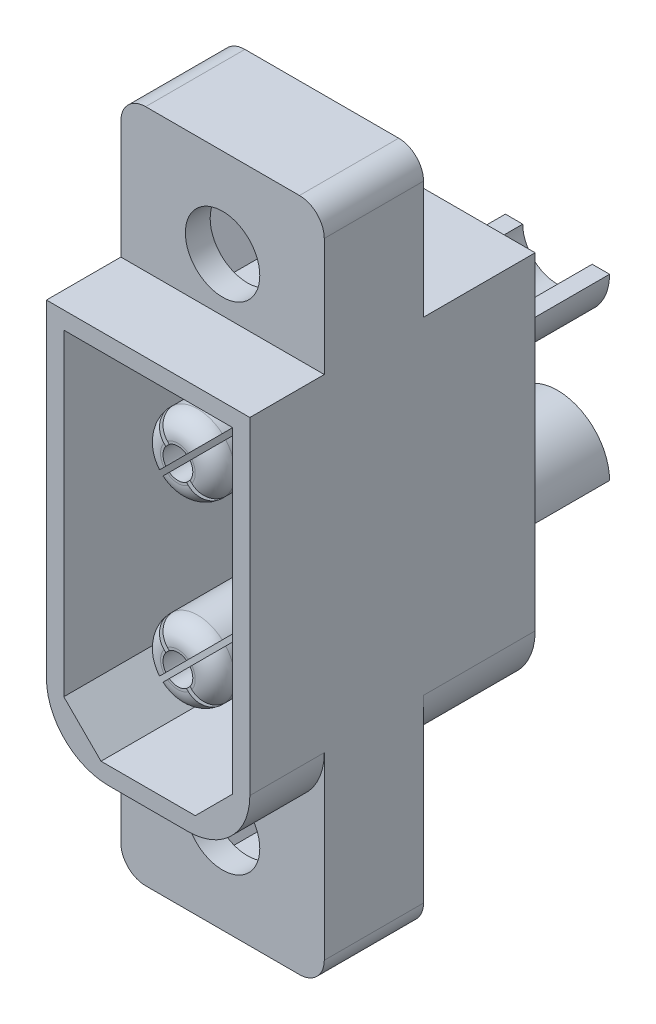
from build123d import *

# Parameters (mm, degrees)
ESTRUSIONE_ESTRUSIONE1_DEPTH  = 4
SCHIZZO2_R                    = 1.5
TAGLIO_ESTRUSIONE1_DEPTH      = 1
TAGLIO_ESTRUSIONE1_DEPTH_BACK = 5
ESTRUSIONE_ESTRUSIONE3_DEPTH  = 3
ESTRUSIONE_ESTRUSIONE4_DEPTH  = 4.5
TAGLIO_ESTRUSIONE2_DEPTH      = 9.5
TAGLIO_ESTRUSIONE3_DEPTH      = 1
SCHIZZO8_R                    = 2.1
ESTRUSIONE_ESTRUSIONE5_DEPTH  = 6
SCHIZZO9_W                    = 5.274732364
SCHIZZO9_H                    = 2.507546262
TAGLIO_ESTRUSIONE4_DEPTH      = 3.2
SCHIZZO10_R                   = 1.4
TAGLIO_ESTRUSIONE5_DEPTH      = 6
RACCORDO1_R                   = 1
TAGLIO_ESTRUSIONE6_DEPTH      = 6
SCHIZZO12_R                   = 1.5
ESTRUSIONE_ESTRUSIONE6_DEPTH  = 8.3
RACCORDO2_R                   = 0.8
TAGLIO_ESTRUSIONE7_DEPTH      = 7
TAGLIO_ESTRUSIONE8_DEPTH      = 3


with BuildPart() as part:
    # Schizzo1 → Estrusione-Estrusione1 (new body)
    with BuildSketch(Plane.XY):
        with BuildLine():
            Line((-3.1, 13.6), (3.1, 13.6))
            ThreePointArc((3.1, 13.6), (3.807106781, 13.307106781), (4.1, 12.6))
            Line((4.1, 12.6), (4.1, -12.6))
            ThreePointArc((4.1, -12.6), (3.807106781, -13.307106781), (3.1, -13.6))
            Line((3.1, -13.6), (-3.1, -13.6))
            ThreePointArc((-3.1, -13.6), (-3.807106781, -13.307106781), (-4.1, -12.6))
            Line((-4.1, -12.6), (-4.1, 12.6))
            ThreePointArc((-4.1, 12.6), (-3.807106781, 13.307106781), (-3.1, 13.6))
        make_face()
    extrude(amount=ESTRUSIONE_ESTRUSIONE1_DEPTH)

    # Schizzo2 → Taglio-Estrusione1 (cut, two sides)
    with BuildSketch(Plane.XY.offset(4)) as taglio_estrusione1_sk:
        with Locations((0, 10)):
            Circle(SCHIZZO2_R)
        with Locations((0, -10)):
            Circle(SCHIZZO2_R)
    extrude(amount=TAGLIO_ESTRUSIONE1_DEPTH, mode=Mode.SUBTRACT)
    extrude(taglio_estrusione1_sk.sketch, amount=-TAGLIO_ESTRUSIONE1_DEPTH_BACK, mode=Mode.SUBTRACT)

    # Schizzo4 → Estrusione-Estrusione3 (add)
    with BuildSketch(Plane.XY.offset(4)):
        with BuildLine():
            Line((-4.1, 7.85), (4.1, 7.85))
            Line((4.1, 7.85), (4.1, -5.35))
            ThreePointArc((4.1, -5.35), (3.367766953, -7.117766953), (1.6, -7.85))
            Line((1.6, -7.85), (-1.6, -7.85))
            ThreePointArc((-1.6, -7.85), (-3.367766953, -7.117766953), (-4.1, -5.35))
            Line((-4.1, -5.35), (-4.1, 7.85))
        make_face()
    extrude(amount=ESTRUSIONE_ESTRUSIONE3_DEPTH)

    # Schizzo5 → Estrusione-Estrusione4 (add)
    with BuildSketch(Plane(origin=(0, 0, 0), x_dir=(-1, 0, 0), z_dir=(0, 0, -1))):
        with BuildLine():
            Line((-1.6, -7.85), (1.6, -7.85))
            ThreePointArc((1.6, -7.85), (3.367766953, -7.117766953), (4.1, -5.35))
            Line((4.1, -5.35), (4.1, 7.85))
            Line((4.1, 7.85), (-4.1, 7.85))
            Line((-4.1, 7.85), (-4.1, -5.35))
            ThreePointArc((-4.1, -5.35), (-3.367766953, -7.117766953), (-1.6, -7.85))
        make_face()
    extrude(amount=ESTRUSIONE_ESTRUSIONE4_DEPTH)

    # Schizzo6 → Taglio-Estrusione2 (cut)
    with BuildSketch(Plane.XY.offset(7)):
        Polygon((1.9, -7.15), (3.4, -5.65), (3.4, 7.15), (-3.4, 7.15), (-3.4, -5.65), (-1.9, -7.15), align=None)
    extrude(amount=-TAGLIO_ESTRUSIONE2_DEPTH, mode=Mode.SUBTRACT)

    # Schizzo7 → Taglio-Estrusione3 (cut)
    with BuildSketch(Plane(origin=(0, 0, -4.5), x_dir=(-1, 0, 0), z_dir=(0, 0, -1))):
        with BuildLine():
            Line((3.4, -5.35), (3.4, 7.15))
            Line((3.4, 7.15), (-3.4, 7.15))
            Line((-3.4, 7.15), (-3.4, -5.35))
            ThreePointArc((-3.4, -5.35), (-2.872792206, -6.622792206), (-1.6, -7.15))
            Line((-1.6, -7.15), (1.6, -7.15))
            ThreePointArc((1.6, -7.15), (2.872792206, -6.622792206), (3.4, -5.35))
        make_face()
    extrude(amount=-TAGLIO_ESTRUSIONE3_DEPTH, mode=Mode.SUBTRACT)

    # Schizzo8 → Estrusione-Estrusione5 (add)
    with BuildSketch(Plane(origin=(0, 0, -3.5), x_dir=(-1, 0, 0), z_dir=(0, 0, -1))):
        with Locations((0, -3.6)):
            Circle(SCHIZZO8_R)
        with Locations((0, 3.6)):
            Circle(SCHIZZO8_R)
    extrude(amount=ESTRUSIONE_ESTRUSIONE5_DEPTH)

    # Schizzo9 → Taglio-Estrusione4 (cut)
    with BuildSketch(Plane(origin=(0, 0, -9.5), x_dir=(-1, 0, 0), z_dir=(0, 0, -1))):
        Polygon((2.1, 3.6), (-2.1, 3.6), (-2.633624999, 3.6), (-2.633624999, 6.426615768), (2.641107365, 6.426615768), (2.641107365, 3.6), align=None)
        with Locations((0.003741183, -4.853773131)):
            Rectangle(SCHIZZO9_W, SCHIZZO9_H)
    extrude(amount=-TAGLIO_ESTRUSIONE4_DEPTH, mode=Mode.SUBTRACT)

    # Schizzo10 → Taglio-Estrusione5 (cut)
    with BuildSketch(Plane(origin=(0, 0, -9.5), x_dir=(-1, 0, 0), z_dir=(0, 0, -1))):
        with Locations((0, 3.6)):
            Circle(SCHIZZO10_R)
        with Locations((0, -3.6)):
            Circle(SCHIZZO10_R)
    extrude(amount=-TAGLIO_ESTRUSIONE5_DEPTH, mode=Mode.SUBTRACT)

    # Raccordo1
    raccordo1_edges = [part.edges().sort_by_distance(p)[0] for p in [
        (1.4, 3.6, -3.5),
        (1.4, -3.6, -3.5),
    ]]
    fillet(raccordo1_edges, radius=RACCORDO1_R)

    # Schizzo11 → Taglio-Estrusione6 (cut)
    with BuildSketch(Plane(origin=(0, 0, -3.5), x_dir=(-1, 0, 0), z_dir=(0, 0, -1))):
        with BuildLine():
            Line((2.6, 1.65), (2.6, -1.65))
            ThreePointArc((2.6, -1.65), (-0.992976067, -0.50540818), (-3.249176734, -3.526852537))
            Line((-3.249176734, -3.526852537), (-3.25, 3.6))
            ThreePointArc((-3.25, 3.6), (-1.02774024, 0.516779281), (2.6, 1.65))
        make_face()
    extrude(amount=-TAGLIO_ESTRUSIONE6_DEPTH, mode=Mode.SUBTRACT)

    # Schizzo12 → Estrusione-Estrusione6 (add)
    with BuildSketch(Plane.XY.offset(-2.5)):
        with Locations((0, -3.6)):
            Circle(SCHIZZO12_R)
        with Locations((0, 3.6)):
            Circle(SCHIZZO12_R)
    extrude(amount=ESTRUSIONE_ESTRUSIONE6_DEPTH)

    # Raccordo2
    raccordo2_edges = [part.edges().sort_by_distance(p)[0] for p in [
        (-1.5, -3.6, 5.8),
        (-1.5, 3.6, 5.8),
    ]]
    fillet(raccordo2_edges, radius=RACCORDO2_R)

    # Schizzo14 → Taglio-Estrusione7 (cut)
    with BuildSketch(Plane.XY.offset(5.8)):
        with BuildLine():
            Line((1.13137085, 2.610050506), (1.202081528, 2.539339828))
            Line((1.202081528, 2.539339828), (1.060660172, 2.397918472))
            Line((1.060660172, 2.397918472), (0.989949494, 2.46862915))
            Line((0.989949494, 2.46862915), (0.347619335, 3.110959309))
            ThreePointArc((0.347619335, 3.110959309), (0, 3), (-0.347619335, 3.110959309))
            Line((-0.347619335, 3.110959309), (-0.989949494, 2.46862915))
            Line((-0.989949494, 2.46862915), (-1.064710345, 2.377203033))
            Line((-1.064710345, 2.377203033), (-1.214464334, 2.526957022))
            Line((-1.214464334, 2.526957022), (-1.13137085, 2.610050506))
            Line((-1.13137085, 2.610050506), (-0.489040691, 3.252380665))
            ThreePointArc((-0.489040691, 3.252380665), (-0.6, 3.6), (-0.489040691, 3.947619335))
            Line((-0.489040691, 3.947619335), (-1.13137085, 4.589949494))
            Line((-1.13137085, 4.589949494), (-1.214464334, 4.656377711))
            Line((-1.214464334, 4.656377711), (-1.064710345, 4.806131701))
            Line((-1.064710345, 4.806131701), (-0.989949494, 4.73137085))
            Line((-0.989949494, 4.73137085), (-0.347619335, 4.089040691))
            ThreePointArc((-0.347619335, 4.089040691), (0, 4.2), (0.347619335, 4.089040691))
            Line((0.347619335, 4.089040691), (0.989949494, 4.73137085))
            Line((0.989949494, 4.73137085), (1.060660172, 4.802081528))
            Line((1.060660172, 4.802081528), (1.202081528, 4.660660172))
            Line((1.202081528, 4.660660172), (1.13137085, 4.589949494))
            Line((1.13137085, 4.589949494), (0.489040691, 3.947619335))
            ThreePointArc((0.489040691, 3.947619335), (0.6, 3.6), (0.489040691, 3.252380665))
            Line((0.489040691, 3.252380665), (1.13137085, 2.610050506))
        make_face()
        with BuildLine():
            Line((-0.989949494, -2.46862915), (-0.347619335, -3.110959309))
            ThreePointArc((-0.347619335, -3.110959309), (0, -3), (0.347619335, -3.110959309))
            Line((0.347619335, -3.110959309), (0.989949494, -2.46862915))
            Line((0.989949494, -2.46862915), (1.060660172, -2.397918472))
            Line((1.060660172, -2.397918472), (1.202081528, -2.539339828))
            Line((1.202081528, -2.539339828), (1.13137085, -2.610050506))
            Line((1.13137085, -2.610050506), (0.489040691, -3.252380665))
            ThreePointArc((0.489040691, -3.252380665), (0.6, -3.6), (0.489040691, -3.947619335))
            Line((0.489040691, -3.947619335), (1.13137085, -4.589949494))
            Line((1.13137085, -4.589949494), (1.202081528, -4.660660172))
            Line((1.202081528, -4.660660172), (1.060660172, -4.802081528))
            Line((1.060660172, -4.802081528), (0.989949494, -4.73137085))
            Line((0.989949494, -4.73137085), (0.347619335, -4.089040691))
            ThreePointArc((0.347619335, -4.089040691), (0, -4.2), (-0.347619335, -4.089040691))
            Line((-0.347619335, -4.089040691), (-0.989949494, -4.73137085))
            Line((-0.989949494, -4.73137085), (-1.064710345, -4.822796967))
            Line((-1.064710345, -4.822796967), (-1.214464334, -4.673042978))
            Line((-1.214464334, -4.673042978), (-1.13137085, -4.589949494))
            Line((-1.13137085, -4.589949494), (-0.489040691, -3.947619335))
            ThreePointArc((-0.489040691, -3.947619335), (-0.6, -3.6), (-0.489040691, -3.252380665))
            Line((-0.489040691, -3.252380665), (-1.13137085, -2.610050506))
            Line((-1.13137085, -2.610050506), (-1.214464334, -2.543622289))
            Line((-1.214464334, -2.543622289), (-1.064710345, -2.393868299))
            Line((-1.064710345, -2.393868299), (-0.989949494, -2.46862915))
        make_face()
    extrude(amount=-TAGLIO_ESTRUSIONE7_DEPTH, mode=Mode.SUBTRACT)

    # Schizzo15 → Taglio-Estrusione8 (cut)
    with BuildSketch(Plane(origin=(0, 0, 0), x_dir=(-1, 0, 0), z_dir=(0, 0, -1))):
        Polygon((2.367136104, -10), (1.183568052, -7.95), (-1.183568052, -7.95), (-2.367136104, -10), (-1.183568052, -12.05), (1.183568052, -12.05), align=None)
        Polygon((2.367136104, 10), (1.183568052, 12.05), (-1.183568052, 12.05), (-2.367136104, 10), (-1.183568052, 7.95), (1.183568052, 7.95), align=None)
    extrude(amount=-TAGLIO_ESTRUSIONE8_DEPTH, mode=Mode.SUBTRACT)


solid = part.part
